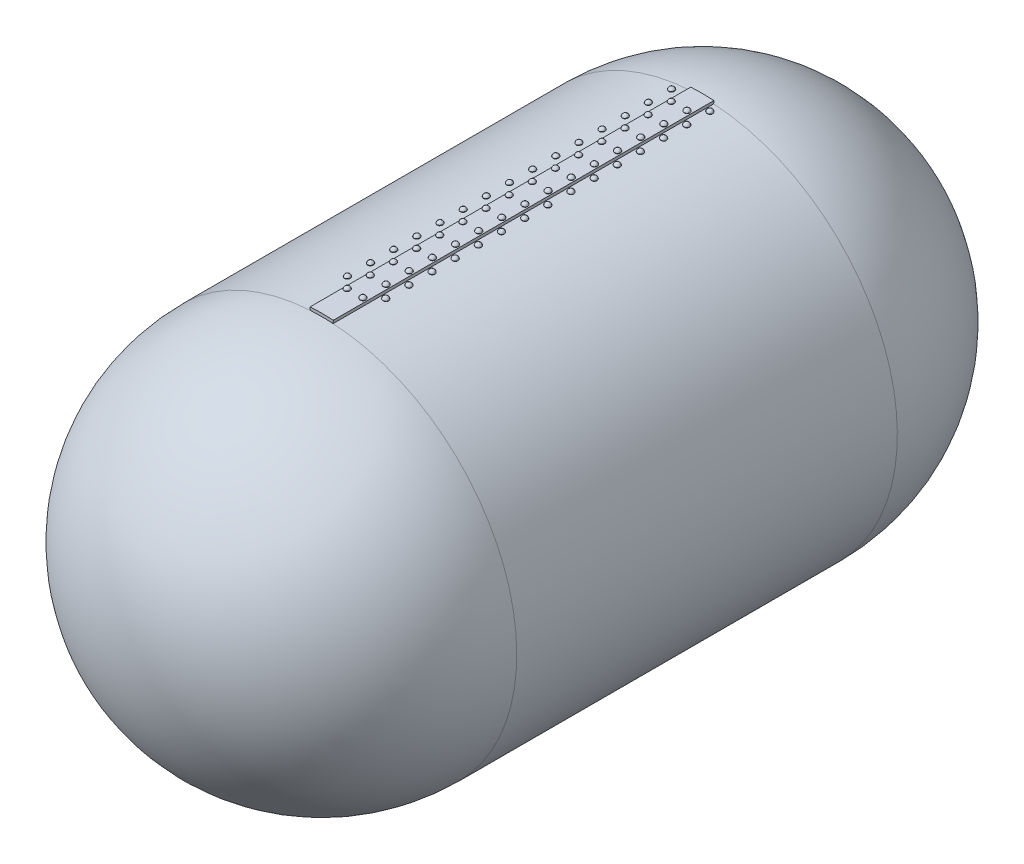
from build123d import *

# Parameters (mm, degrees)
SKETCH1_R           = 1200
BOSS_EXTRUDE1_DEPTH = 2400
LPATTERN1_COUNT     = 15
LPATTERN1_PITCH     = 146
LPATTERN2_COUNT     = 15
LPATTERN2_PITCH     = 146
LPATTERN3_COUNT     = 15
LPATTERN3_PITCH     = 146
LPATTERN4_COUNT     = 15
LPATTERN4_PITCH     = 146


with BuildPart() as part:
    # Sketch1 → Boss-Extrude1 (new body)
    with BuildSketch(Plane.XY):
        with BuildLine():
            ThreePointArc((73.124826909, 1246.857553889), (0, 1249), (-73.124826909, 1246.857553889))
            Line((-73.124826909, 1246.857553889), (-72.01243963, 1227.890145143))
            ThreePointArc((-72.01243963, 1227.890145143), (0, -1230), (72.01243963, 1227.890145143))
            Line((72.01243963, 1227.890145143), (73.124826909, 1246.857553889))
        make_face()
        Circle(SKETCH1_R, mode=Mode.SUBTRACT)
    extrude(amount=BOSS_EXTRUDE1_DEPTH)

    # Sketch7 → Revolve3 (revolve)
    with BuildSketch(Plane(origin=(0, 0, 0), x_dir=(0, 0, -1), z_dir=(1, 0, 0))):
        with BuildLine():
            Line((0, 0), (0, -1230))
            ThreePointArc((0, -1230), (869.741340859, -869.741340859), (1230, 0))
            Line((1230, 0), (0, 0))
        make_face()
    revolve3 = revolve(axis=Axis((0, 0, 0), (0, 0, -1)))

    # Mirror2: Revolve3 across plane
    add(revolve3.mirror(Plane.XY.offset(1200)))


with BuildPart() as body_2:
    # Sketch4 → Revolve1 (revolve)
    with BuildSketch(Plane.XY.offset(146)):
        Polygon((-49.487042973, 1248.019243673), (-65.974086624, 1247.365491704), (-68.517224389, 1251.392891648), (-49.650480965, 1252.141004586), align=None)
    revolve(axis=Axis((-49.487042973, 1248.019243673, 146), (0.039621331, -0.999214767, 0)))

    # Sketch6 → Revolve2 (revolve)
    with BuildSketch(Plane.XY.offset(146)):
        with BuildLine():
            Line((-49.650480965, 1252.141004586), (-50.279183422, 1267.996321817))
            ThreePointArc((-50.279183422, 1267.996321817), (-62.423323434, 1263.017549843), (-68.517224389, 1251.392891648))
            Line((-68.517224389, 1251.392891648), (-49.650480965, 1252.141004586))
        make_face()
    revolve(axis=Axis((-49.650480965, 1252.141004586, 146), (-0.039621331, 0.999214767, 0)))


with BuildPart() as body_3:
    # Mirror1: mirrored copy
    add(body_2.part.mirror(Plane(origin=(0, 0, 0), x_dir=(0, 0, 1), z_dir=(1, 0, 0))))


with BuildPart() as lpattern1_1:
    # LPattern1: pattern copy
    add(body_2.part.moved(Location(Vector(0, 0, 1) * (1 * LPATTERN1_PITCH))))


with BuildPart() as lpattern1_2:
    # LPattern1: pattern copy
    add(body_2.part.moved(Location(Vector(0, 0, 1) * (2 * LPATTERN1_PITCH))))


with BuildPart() as lpattern1_3:
    # LPattern1: pattern copy
    add(body_2.part.moved(Location(Vector(0, 0, 1) * (3 * LPATTERN1_PITCH))))


with BuildPart() as lpattern1_4:
    # LPattern1: pattern copy
    add(body_2.part.moved(Location(Vector(0, 0, 1) * (4 * LPATTERN1_PITCH))))


with BuildPart() as lpattern1_5:
    # LPattern1: pattern copy
    add(body_2.part.moved(Location(Vector(0, 0, 1) * (5 * LPATTERN1_PITCH))))


with BuildPart() as lpattern1_6:
    # LPattern1: pattern copy
    add(body_2.part.moved(Location(Vector(0, 0, 1) * (6 * LPATTERN1_PITCH))))


with BuildPart() as lpattern1_7:
    # LPattern1: pattern copy
    add(body_2.part.moved(Location(Vector(0, 0, 1) * (7 * LPATTERN1_PITCH))))


with BuildPart() as lpattern1_8:
    # LPattern1: pattern copy
    add(body_2.part.moved(Location(Vector(0, 0, 1) * (8 * LPATTERN1_PITCH))))


with BuildPart() as lpattern1_9:
    # LPattern1: pattern copy
    add(body_2.part.moved(Location(Vector(0, 0, 1) * (9 * LPATTERN1_PITCH))))


with BuildPart() as lpattern1_10:
    # LPattern1: pattern copy
    add(body_2.part.moved(Location(Vector(0, 0, 1) * (10 * LPATTERN1_PITCH))))


with BuildPart() as lpattern1_11:
    # LPattern1: pattern copy
    add(body_2.part.moved(Location(Vector(0, 0, 1) * (11 * LPATTERN1_PITCH))))


with BuildPart() as lpattern1_12:
    # LPattern1: pattern copy
    add(body_2.part.moved(Location(Vector(0, 0, 1) * (12 * LPATTERN1_PITCH))))


with BuildPart() as lpattern1_13:
    # LPattern1: pattern copy
    add(body_2.part.moved(Location(Vector(0, 0, 1) * (13 * LPATTERN1_PITCH))))


with BuildPart() as lpattern1_14:
    # LPattern1: pattern copy
    add(body_2.part.moved(Location(Vector(0, 0, 1) * (14 * LPATTERN1_PITCH))))


with BuildPart() as lpattern2_1:
    # LPattern2: pattern copy
    add(body_3.part.moved(Location(Vector(0, 0, 1) * (1 * LPATTERN2_PITCH))))


with BuildPart() as lpattern2_2:
    # LPattern2: pattern copy
    add(body_3.part.moved(Location(Vector(0, 0, 1) * (2 * LPATTERN2_PITCH))))


with BuildPart() as lpattern2_3:
    # LPattern2: pattern copy
    add(body_3.part.moved(Location(Vector(0, 0, 1) * (3 * LPATTERN2_PITCH))))


with BuildPart() as lpattern2_4:
    # LPattern2: pattern copy
    add(body_3.part.moved(Location(Vector(0, 0, 1) * (4 * LPATTERN2_PITCH))))


with BuildPart() as lpattern2_5:
    # LPattern2: pattern copy
    add(body_3.part.moved(Location(Vector(0, 0, 1) * (5 * LPATTERN2_PITCH))))


with BuildPart() as lpattern2_6:
    # LPattern2: pattern copy
    add(body_3.part.moved(Location(Vector(0, 0, 1) * (6 * LPATTERN2_PITCH))))


with BuildPart() as lpattern2_7:
    # LPattern2: pattern copy
    add(body_3.part.moved(Location(Vector(0, 0, 1) * (7 * LPATTERN2_PITCH))))


with BuildPart() as lpattern2_8:
    # LPattern2: pattern copy
    add(body_3.part.moved(Location(Vector(0, 0, 1) * (8 * LPATTERN2_PITCH))))


with BuildPart() as lpattern2_9:
    # LPattern2: pattern copy
    add(body_3.part.moved(Location(Vector(0, 0, 1) * (9 * LPATTERN2_PITCH))))


with BuildPart() as lpattern2_10:
    # LPattern2: pattern copy
    add(body_3.part.moved(Location(Vector(0, 0, 1) * (10 * LPATTERN2_PITCH))))


with BuildPart() as lpattern2_11:
    # LPattern2: pattern copy
    add(body_3.part.moved(Location(Vector(0, 0, 1) * (11 * LPATTERN2_PITCH))))


with BuildPart() as lpattern2_12:
    # LPattern2: pattern copy
    add(body_3.part.moved(Location(Vector(0, 0, 1) * (12 * LPATTERN2_PITCH))))


with BuildPart() as lpattern2_13:
    # LPattern2: pattern copy
    add(body_3.part.moved(Location(Vector(0, 0, 1) * (13 * LPATTERN2_PITCH))))


with BuildPart() as lpattern2_14:
    # LPattern2: pattern copy
    add(body_3.part.moved(Location(Vector(0, 0, 1) * (14 * LPATTERN2_PITCH))))


with BuildPart() as body_32:
    # Sketch9 → Revolve4 (revolve)
    with BuildSketch(Plane.XY.offset(73)):
        Polygon((120.313154392, 1243.191757083), (103.889884583, 1244.781162246), (101.916741062, 1249.116390572), (120.710505682, 1247.297574536), align=None)
    revolve(axis=Axis((120.313154392, 1243.191757083, 73), (0.096327586, 0.995349685, 0)))

    # Sketch11 → Revolve5 (revolve)
    with BuildSketch(Plane.XY.offset(73)):
        with BuildLine():
            Line((120.710505682, 1247.297574536), (122.239010343, 1263.091561518))
            ThreePointArc((122.239010343, 1263.091561518), (109.531620976, 1259.80666236), (101.916741062, 1249.116390572))
            Line((101.916741062, 1249.116390572), (120.710505682, 1247.297574536))
        make_face()
    revolve(axis=Axis((120.710505682, 1247.297574536, 73), (0.096327586, 0.995349685, 0)))


with BuildPart() as body_33:
    # Mirror3: mirrored copy
    add(body_32.part.mirror(Plane(origin=(0, 0, 0), x_dir=(0, 0, 1), z_dir=(1, 0, 0))))


with BuildPart() as lpattern3_1:
    # LPattern3: pattern copy
    add(body_32.part.moved(Location(Vector(0, 0, 1) * (1 * LPATTERN3_PITCH))))


with BuildPart() as lpattern3_2:
    # LPattern3: pattern copy
    add(body_32.part.moved(Location(Vector(0, 0, 1) * (2 * LPATTERN3_PITCH))))


with BuildPart() as lpattern3_3:
    # LPattern3: pattern copy
    add(body_32.part.moved(Location(Vector(0, 0, 1) * (3 * LPATTERN3_PITCH))))


with BuildPart() as lpattern3_4:
    # LPattern3: pattern copy
    add(body_32.part.moved(Location(Vector(0, 0, 1) * (4 * LPATTERN3_PITCH))))


with BuildPart() as lpattern3_5:
    # LPattern3: pattern copy
    add(body_32.part.moved(Location(Vector(0, 0, 1) * (5 * LPATTERN3_PITCH))))


with BuildPart() as lpattern3_6:
    # LPattern3: pattern copy
    add(body_32.part.moved(Location(Vector(0, 0, 1) * (6 * LPATTERN3_PITCH))))


with BuildPart() as lpattern3_7:
    # LPattern3: pattern copy
    add(body_32.part.moved(Location(Vector(0, 0, 1) * (7 * LPATTERN3_PITCH))))


with BuildPart() as lpattern3_8:
    # LPattern3: pattern copy
    add(body_32.part.moved(Location(Vector(0, 0, 1) * (8 * LPATTERN3_PITCH))))


with BuildPart() as lpattern3_9:
    # LPattern3: pattern copy
    add(body_32.part.moved(Location(Vector(0, 0, 1) * (9 * LPATTERN3_PITCH))))


with BuildPart() as lpattern3_10:
    # LPattern3: pattern copy
    add(body_32.part.moved(Location(Vector(0, 0, 1) * (10 * LPATTERN3_PITCH))))


with BuildPart() as lpattern3_11:
    # LPattern3: pattern copy
    add(body_32.part.moved(Location(Vector(0, 0, 1) * (11 * LPATTERN3_PITCH))))


with BuildPart() as lpattern3_12:
    # LPattern3: pattern copy
    add(body_32.part.moved(Location(Vector(0, 0, 1) * (12 * LPATTERN3_PITCH))))


with BuildPart() as lpattern3_13:
    # LPattern3: pattern copy
    add(body_32.part.moved(Location(Vector(0, 0, 1) * (13 * LPATTERN3_PITCH))))


with BuildPart() as lpattern3_14:
    # LPattern3: pattern copy
    add(body_32.part.moved(Location(Vector(0, 0, 1) * (14 * LPATTERN3_PITCH))))


with BuildPart() as lpattern4_1:
    # LPattern4: pattern copy
    add(body_33.part.moved(Location(Vector(0, 0, 1) * (1 * LPATTERN4_PITCH))))


with BuildPart() as lpattern4_2:
    # LPattern4: pattern copy
    add(body_33.part.moved(Location(Vector(0, 0, 1) * (2 * LPATTERN4_PITCH))))


with BuildPart() as lpattern4_3:
    # LPattern4: pattern copy
    add(body_33.part.moved(Location(Vector(0, 0, 1) * (3 * LPATTERN4_PITCH))))


with BuildPart() as lpattern4_4:
    # LPattern4: pattern copy
    add(body_33.part.moved(Location(Vector(0, 0, 1) * (4 * LPATTERN4_PITCH))))


with BuildPart() as lpattern4_5:
    # LPattern4: pattern copy
    add(body_33.part.moved(Location(Vector(0, 0, 1) * (5 * LPATTERN4_PITCH))))


with BuildPart() as lpattern4_6:
    # LPattern4: pattern copy
    add(body_33.part.moved(Location(Vector(0, 0, 1) * (6 * LPATTERN4_PITCH))))


with BuildPart() as lpattern4_7:
    # LPattern4: pattern copy
    add(body_33.part.moved(Location(Vector(0, 0, 1) * (7 * LPATTERN4_PITCH))))


with BuildPart() as lpattern4_8:
    # LPattern4: pattern copy
    add(body_33.part.moved(Location(Vector(0, 0, 1) * (8 * LPATTERN4_PITCH))))


with BuildPart() as lpattern4_9:
    # LPattern4: pattern copy
    add(body_33.part.moved(Location(Vector(0, 0, 1) * (9 * LPATTERN4_PITCH))))


with BuildPart() as lpattern4_10:
    # LPattern4: pattern copy
    add(body_33.part.moved(Location(Vector(0, 0, 1) * (10 * LPATTERN4_PITCH))))


with BuildPart() as lpattern4_11:
    # LPattern4: pattern copy
    add(body_33.part.moved(Location(Vector(0, 0, 1) * (11 * LPATTERN4_PITCH))))


with BuildPart() as lpattern4_12:
    # LPattern4: pattern copy
    add(body_33.part.moved(Location(Vector(0, 0, 1) * (12 * LPATTERN4_PITCH))))


with BuildPart() as lpattern4_13:
    # LPattern4: pattern copy
    add(body_33.part.moved(Location(Vector(0, 0, 1) * (13 * LPATTERN4_PITCH))))


with BuildPart() as lpattern4_14:
    # LPattern4: pattern copy
    add(body_33.part.moved(Location(Vector(0, 0, 1) * (14 * LPATTERN4_PITCH))))


solid = Compound([part.part, body_2.part, body_3.part, lpattern1_1.part, lpattern1_2.part, lpattern1_3.part, lpattern1_4.part, lpattern1_5.part, lpattern1_6.part, lpattern1_7.part, lpattern1_8.part, lpattern1_9.part, lpattern1_10.part, lpattern1_11.part, lpattern1_12.part, lpattern1_13.part, lpattern1_14.part, lpattern2_1.part, lpattern2_2.part, lpattern2_3.part, lpattern2_4.part, lpattern2_5.part, lpattern2_6.part, lpattern2_7.part, lpattern2_8.part, lpattern2_9.part, lpattern2_10.part, lpattern2_11.part, lpattern2_12.part, lpattern2_13.part, lpattern2_14.part, body_32.part, body_33.part, lpattern3_1.part, lpattern3_2.part, lpattern3_3.part, lpattern3_4.part, lpattern3_5.part, lpattern3_6.part, lpattern3_7.part, lpattern3_8.part, lpattern3_9.part, lpattern3_10.part, lpattern3_11.part, lpattern3_12.part, lpattern3_13.part, lpattern3_14.part, lpattern4_1.part, lpattern4_2.part, lpattern4_3.part, lpattern4_4.part, lpattern4_5.part, lpattern4_6.part, lpattern4_7.part, lpattern4_8.part, lpattern4_9.part, lpattern4_10.part, lpattern4_11.part, lpattern4_12.part, lpattern4_13.part, lpattern4_14.part])
